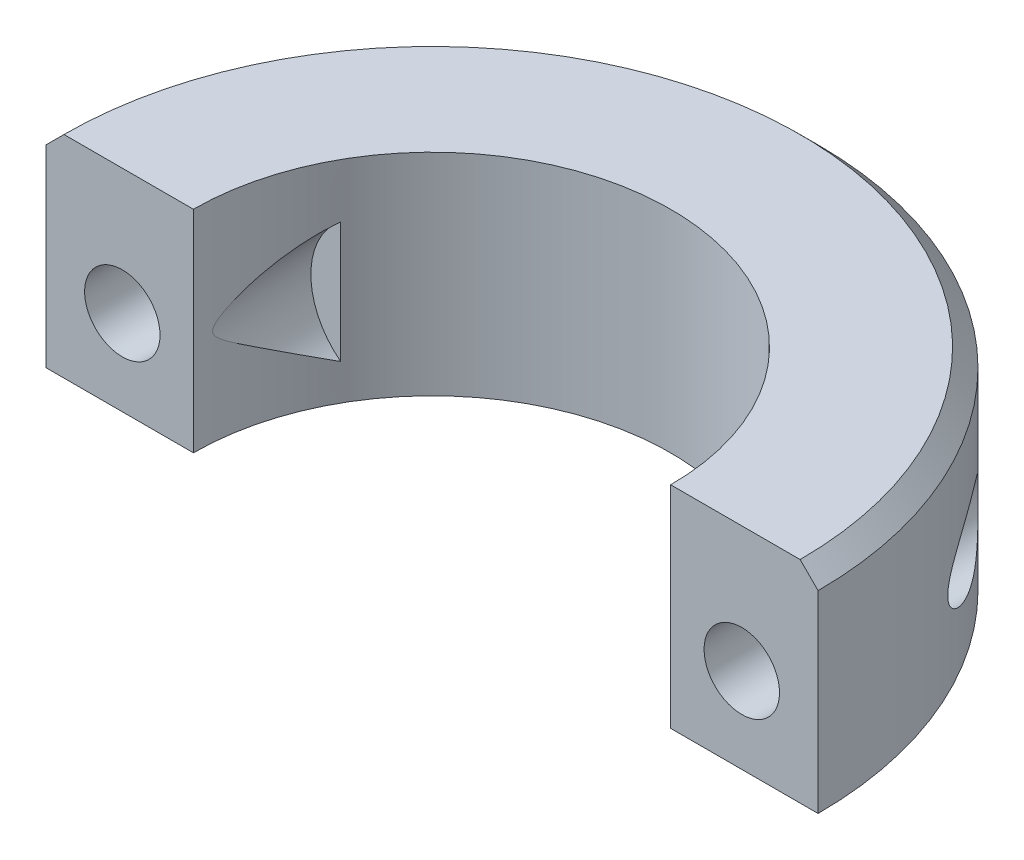
from build123d import *

# Parameters (mm, degrees)
BOSS_EXTRUDE1_DEPTH = 5.875
CHAMFER1_SIZE       = 1
SKETCH2_R           = 2.1
CUT_EXTRUDE1_DEPTH  = 22.5
SKETCH3_R           = 4.25
CUT_EXTRUDE2_DEPTH  = 6.5


with BuildPart() as part:
    # Sketch1 → Boss-Extrude1 (new body, symmetric)
    with BuildSketch(Plane(origin=(0, 0, 0), x_dir=(1, 0, 0), z_dir=(0, 1, 0))):
        with BuildLine():
            Line((-21.5, 0), (-13.29, 0))
            ThreePointArc((-13.29, 0), (0, 13.29), (13.29, 0))
            Line((13.29, 0), (21.5, 0))
            ThreePointArc((21.5, 0), (0, 21.5), (-21.5, 0))
        make_face()
    extrude(amount=BOSS_EXTRUDE1_DEPTH, both=True)

    # Chamfer1
    chamfer1_edges = [part.edges().sort_by_distance(p)[0] for p in [
        (0, 5.875, -21.5),
    ]]
    chamfer(chamfer1_edges, length=CHAMFER1_SIZE)

    # Sketch2 → Cut-Extrude1 (cut, through all)
    with BuildSketch(Plane.XY):
        with Locations((-17.25, -1.125)):
            Circle(SKETCH2_R)
        with Locations((17.25, -1.125)):
            Circle(SKETCH2_R)
    extrude(amount=-CUT_EXTRUDE1_DEPTH, mode=Mode.SUBTRACT)

    # Sketch3 → Cut-Extrude2 (cut)
    with BuildSketch(Plane.XY):
        with Locations((-9, -0.5)):
            Circle(SKETCH3_R)
        with Locations((9, -0.5)):
            Circle(SKETCH3_R)
    extrude(amount=-CUT_EXTRUDE2_DEPTH, mode=Mode.SUBTRACT)


solid = part.part
